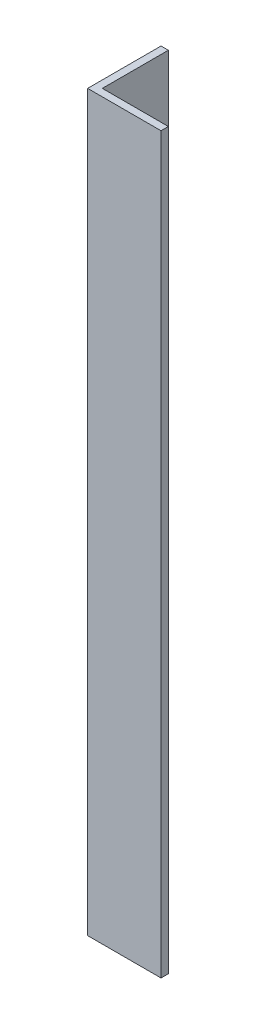
from build123d import *

# Parameters (mm, degrees)
EXTRUDE_1_DEPTH = 400


with BuildPart() as part:
    # Эскиз1 → Вытянуть-Тонкостенный1 (new body)
    with BuildSketch(Plane(origin=(0, 0, 0), x_dir=(1, 0, 0), z_dir=(0, 1, 0))):
        Polygon((0, 40), (0, 0), (40, 0), (40, 4), (4, 4), (4, 40), align=None)
    extrude(amount=EXTRUDE_1_DEPTH)


solid = part.part
